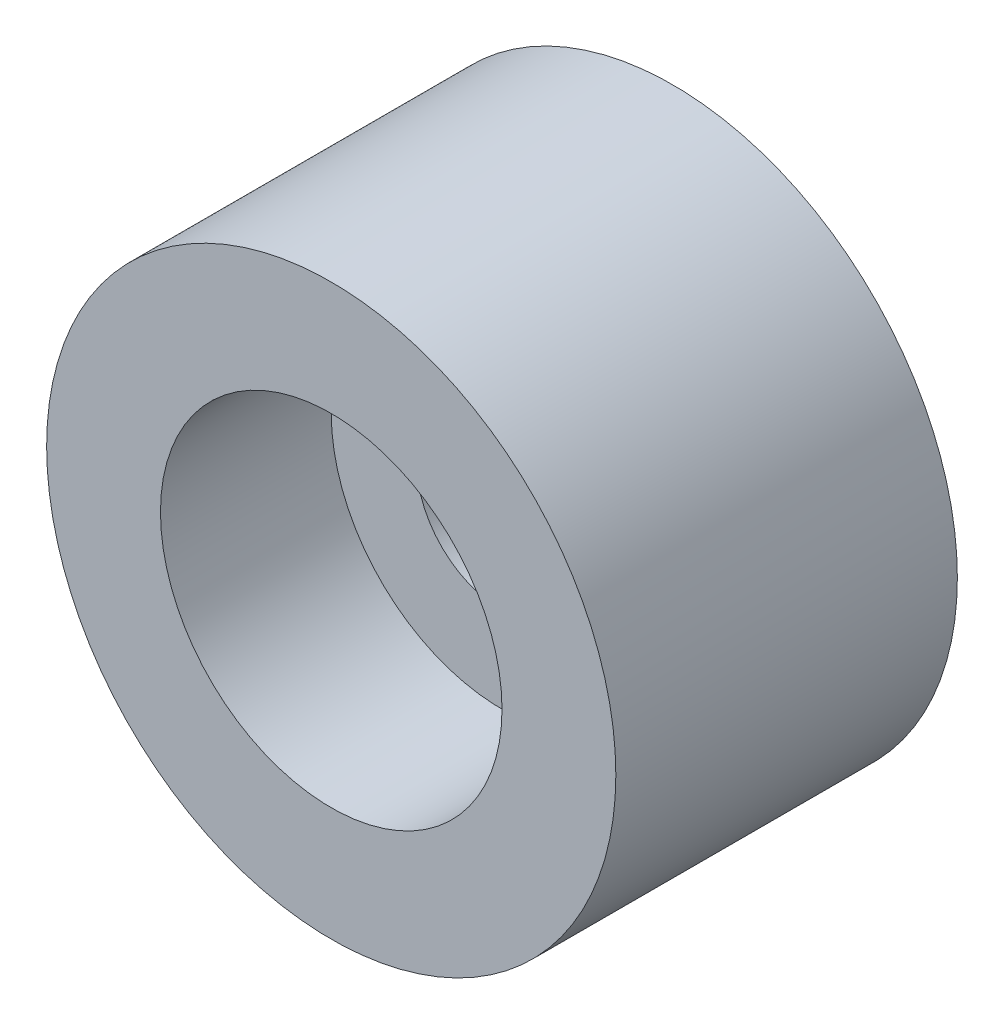
from build123d import *

# Parameters (mm, degrees)
SKETCH_1_R          = 2.5
SKETCH_1_R_2        = 0.75
EXTRUDE_1_DEPTH     = 3
SKETCH_2_R          = 1.5
CUT_EXTRUDE_1_DEPTH = 1.5


with BuildPart() as part:
    # 草图1 → 凸台-拉伸1 (new body)
    with BuildSketch(Plane.XY):
        Circle(SKETCH_1_R)
        Circle(SKETCH_1_R_2, mode=Mode.SUBTRACT)
    extrude(amount=EXTRUDE_1_DEPTH)

    # 草图2 → 切除-拉伸1 (cut)
    with BuildSketch(Plane.XY.offset(3)):
        Circle(SKETCH_2_R)
    extrude(amount=-CUT_EXTRUDE_1_DEPTH, mode=Mode.SUBTRACT)


solid = part.part
